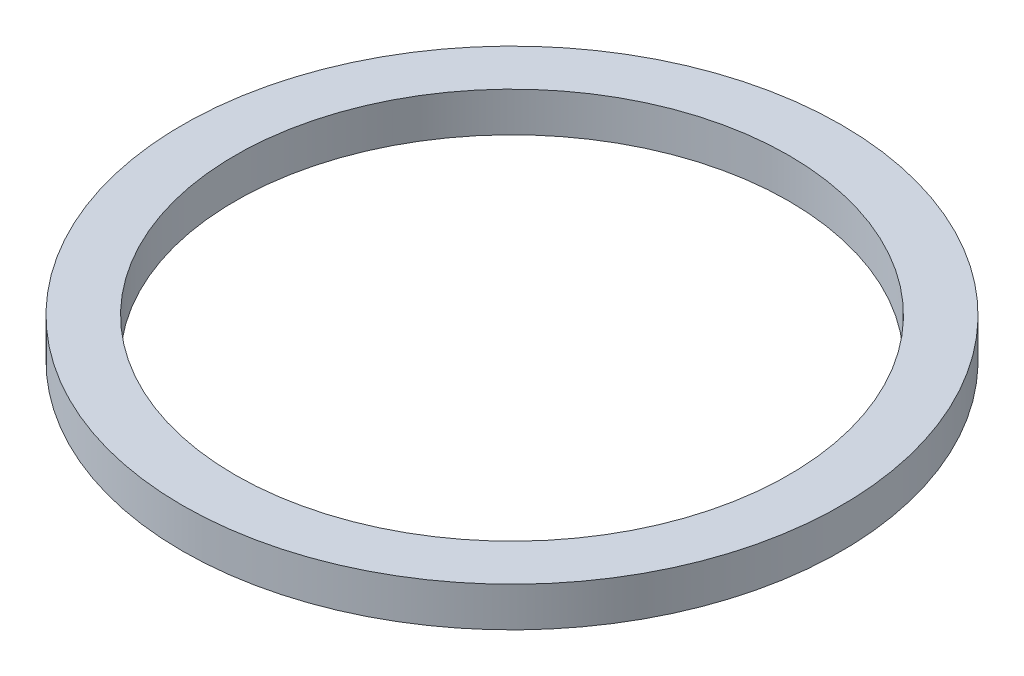
from build123d import *

# Parameters (mm, degrees)
ESQUISSE1_R        = 25
ESQUISSE1_R_2      = 21
BOSS_EXTRU_1_DEPTH = 3


with BuildPart() as part:
    # Esquisse1 → Boss.-Extru.1 (new body)
    with BuildSketch(Plane(origin=(0, 0, 0), x_dir=(1, 0, 0), z_dir=(0, 1, 0))):
        Circle(ESQUISSE1_R)
        Circle(ESQUISSE1_R_2, mode=Mode.SUBTRACT)
    extrude(amount=BOSS_EXTRU_1_DEPTH)


solid = part.part
